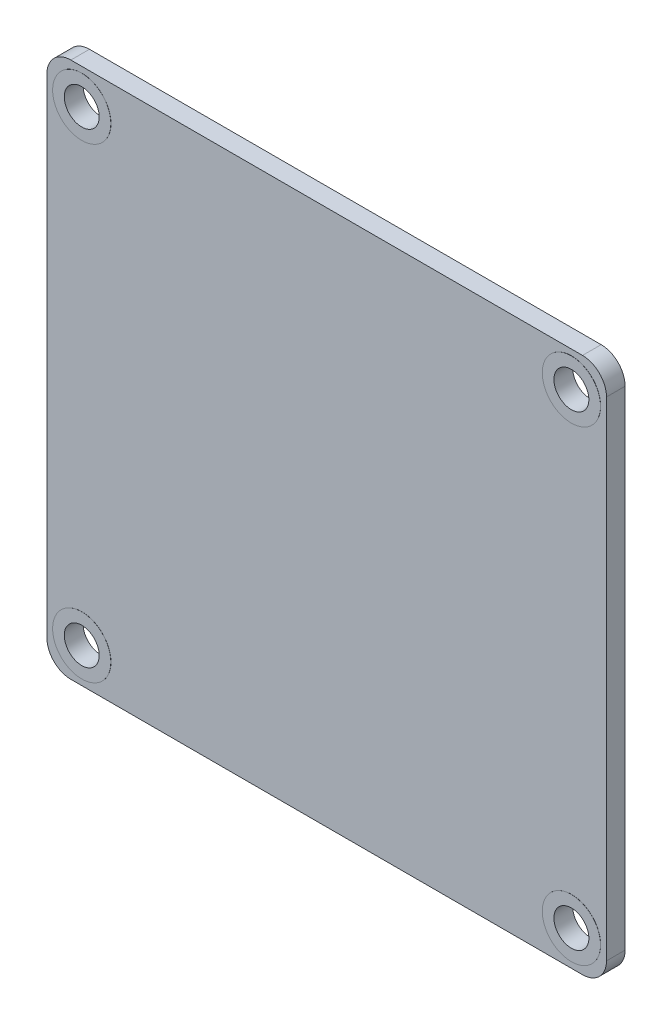
from build123d import *

# Parameters (mm, degrees)
BG_OUTLINE_R                   = 2.5
SALIENTE_EXTRUIR1_DEPTH        = 1.6
CROQUIS5_R                     = 2.5
CROQUIS5_R_2                   = 1.5
SALIENTE_EXTRUIR2_DEPTH        = 0.01
SALIENTE_EXTRUIR2_DEPTH_BACK   = 1.61
SALIENTE_EXTRUIR2_2_DEPTH      = 0.01
SALIENTE_EXTRUIR2_2_DEPTH_BACK = 1.61
SALIENTE_EXTRUIR2_3_DEPTH      = 0.01
SALIENTE_EXTRUIR2_3_DEPTH_BACK = 1.61
SALIENTE_EXTRUIR2_4_DEPTH      = 0.01
SALIENTE_EXTRUIR2_4_DEPTH_BACK = 1.61


with BuildPart() as part:
    # BG_OUTLINE → Saliente-Extruir1 (new body)
    with BuildSketch(Plane.XY):
        with BuildLine():
            Line((101.566907906, 140.330081796), (101.566907906, 98.405907128))
            ThreePointArc((101.566907906, 98.405907128), (102.170201979, 96.949426394), (103.626682714, 96.34613232))
            Line((103.626682714, 96.34613232), (147.547246656, 96.34613232))
            ThreePointArc((147.547246656, 96.34613232), (149.00372739, 96.949426394), (149.607021464, 98.405907128))
            Line((149.607021464, 98.405907128), (149.607021464, 140.330081796))
            ThreePointArc((149.607021464, 140.330081796), (149.00372739, 141.78656253), (147.547246656, 142.389856604))
            Line((147.547246656, 142.389856604), (103.626682714, 142.389856604))
            ThreePointArc((103.626682714, 142.389856604), (102.170201979, 141.78656253), (101.566907906, 140.330081796))
        make_face()
        with Locations((146.604450981, 139.387286121)):
            Circle(BG_OUTLINE_R, mode=Mode.SUBTRACT)
        with Locations((104.569478389, 139.387286121)):
            Circle(BG_OUTLINE_R, mode=Mode.SUBTRACT)
        with Locations((104.569478389, 99.348702803)):
            Circle(BG_OUTLINE_R, mode=Mode.SUBTRACT)
        with Locations((146.604450981, 99.348702803)):
            Circle(BG_OUTLINE_R, mode=Mode.SUBTRACT)
    extrude(amount=SALIENTE_EXTRUIR1_DEPTH)


with BuildPart() as body_2:
    # Croquis5 → Saliente-Extruir2 (new body, two sides)
    with BuildSketch(Plane.XY.offset(1.6)) as saliente_extruir2_sk:
        with Locations((146.604450981, 139.387286121)):
            Circle(CROQUIS5_R)
        with Locations((146.604450981, 139.387286121)):
            Circle(CROQUIS5_R_2, mode=Mode.SUBTRACT)
    extrude(amount=SALIENTE_EXTRUIR2_DEPTH)
    extrude(saliente_extruir2_sk.sketch, amount=-SALIENTE_EXTRUIR2_DEPTH_BACK)


with BuildPart() as body_3:
    # Croquis5 → Saliente-Extruir2 2 (new body, two sides)
    with BuildSketch(Plane.XY.offset(1.6)) as saliente_extruir2_2_sk:
        with Locations((104.569478389, 139.387286121)):
            Circle(CROQUIS5_R)
        with Locations((104.569478389, 139.387286121)):
            Circle(CROQUIS5_R_2, mode=Mode.SUBTRACT)
    extrude(amount=SALIENTE_EXTRUIR2_2_DEPTH)
    extrude(saliente_extruir2_2_sk.sketch, amount=-SALIENTE_EXTRUIR2_2_DEPTH_BACK)


with BuildPart() as body_4:
    # Croquis5 → Saliente-Extruir2 3 (new body, two sides)
    with BuildSketch(Plane.XY.offset(1.6)) as saliente_extruir2_3_sk:
        with Locations((104.569478389, 99.348702803)):
            Circle(CROQUIS5_R)
        with Locations((104.569478389, 99.348702803)):
            Circle(CROQUIS5_R_2, mode=Mode.SUBTRACT)
    extrude(amount=SALIENTE_EXTRUIR2_3_DEPTH)
    extrude(saliente_extruir2_3_sk.sketch, amount=-SALIENTE_EXTRUIR2_3_DEPTH_BACK)


with BuildPart() as body_5:
    # Croquis5 → Saliente-Extruir2 4 (new body, two sides)
    with BuildSketch(Plane.XY.offset(1.6)) as saliente_extruir2_4_sk:
        with Locations((146.604450981, 99.348702803)):
            Circle(CROQUIS5_R)
        with Locations((146.604450981, 99.348702803)):
            Circle(CROQUIS5_R_2, mode=Mode.SUBTRACT)
    extrude(amount=SALIENTE_EXTRUIR2_4_DEPTH)
    extrude(saliente_extruir2_4_sk.sketch, amount=-SALIENTE_EXTRUIR2_4_DEPTH_BACK)


solid = Compound([part.part, body_2.part, body_3.part, body_4.part, body_5.part])
